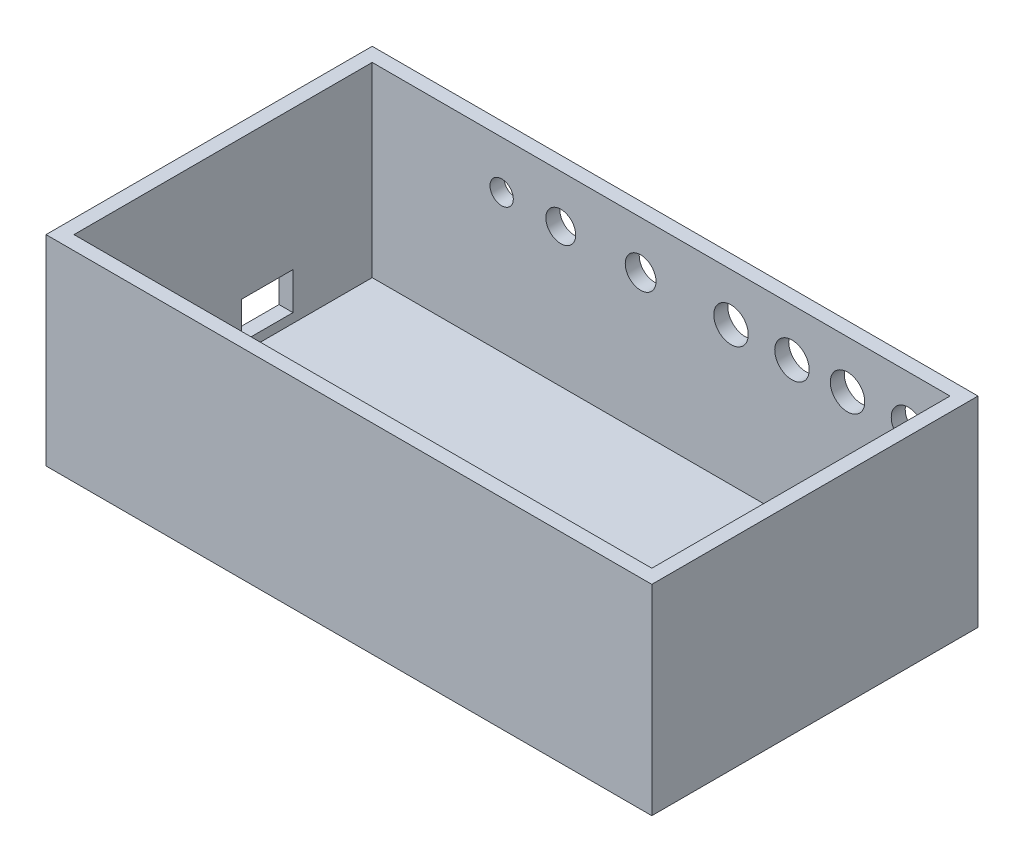
from build123d import *

# Parameters (mm, degrees)
SKETCH5_W           = 130
SKETCH5_H           = 70
BOSS_EXTRUDE3_DEPTH = 43
SKETCH6_W           = 124
SKETCH6_H           = 64
CUT_EXTRUDE3_DEPTH  = 40
SKETCH8_R           = 3.7
CUT_EXTRUDE7_DEPTH  = 40
SKETCH9_R           = 3.3
SKETCH9_R_2         = 3.2
SKETCH9_R_3         = 2.5
CUT_EXTRUDE8_DEPTH  = 40
SKETCH10_W          = 11
SKETCH10_H          = 8
CUT_EXTRUDE9_DEPTH  = 40


with BuildPart() as part:
    # Sketch5 → Boss-Extrude3 (new body)
    with BuildSketch(Plane(origin=(0, 0, 0), x_dir=(1, 0, 0), z_dir=(0, 1, 0))):
        with Locations((65, -35)):
            Rectangle(SKETCH5_W, SKETCH5_H)
    extrude(amount=BOSS_EXTRUDE3_DEPTH)

    # Sketch6 → Cut-Extrude3 (cut)
    with BuildSketch(Plane(origin=(0, 43, 0), x_dir=(1, 0, 0), z_dir=(0, 1, 0))):
        with Locations((65, -35)):
            Rectangle(SKETCH6_W, SKETCH6_H)
    extrude(amount=-CUT_EXTRUDE3_DEPTH, mode=Mode.SUBTRACT)

    # Sketch8 → Cut-Extrude7 (cut)
    with BuildSketch(Plane(origin=(0, 0, 0), x_dir=(-1, 0, 0), z_dir=(0, 0, -1))):
        with Locations((-105, 32.75)):
            Circle(SKETCH8_R)
        with Locations((-93.081395349, 32.75)):
            Circle(SKETCH8_R)
        with Locations((-80, 32.75)):
            Circle(SKETCH8_R)
        with Locations((-118.081395349, 32.75)):
            Circle(SKETCH8_R)
    extrude(amount=-CUT_EXTRUDE7_DEPTH, mode=Mode.SUBTRACT)

    # Sketch9 → Cut-Extrude8 (cut)
    with BuildSketch(Plane(origin=(0, 0, 0), x_dir=(-1, 0, 0), z_dir=(0, 0, -1))):
        with Locations((-60.600049653, 32.75)):
            Circle(SKETCH9_R)
        with Locations((-43.4660788, 32.75)):
            Circle(SKETCH9_R_2)
        with Locations((-30.78166501, 32.75)):
            Circle(SKETCH9_R_3)
    extrude(amount=-CUT_EXTRUDE8_DEPTH, mode=Mode.SUBTRACT)

    # Sketch10 → Cut-Extrude9 (cut)
    with BuildSketch(Plane.ZY):
        with Locations((25.5, 9)):
            Rectangle(SKETCH10_W, SKETCH10_H)
    extrude(amount=-CUT_EXTRUDE9_DEPTH, mode=Mode.SUBTRACT)


solid = part.part
